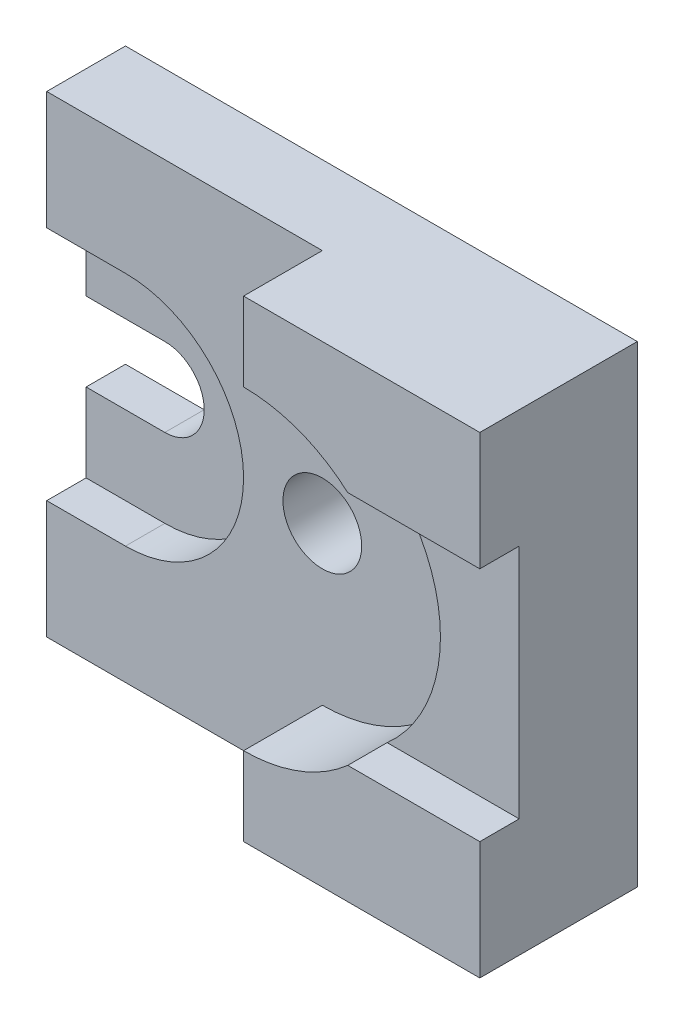
from build123d import *

# Parameters (mm, degrees)
SKETCH1_W           = 130
SKETCH1_H           = 120
BOSS_EXTRUDE1_DEPTH = 40
CUT_EXTRUDE1_DEPTH  = 40
CUT_EXTRUDE2_DEPTH  = 10
SKETCH4_R           = 10
CUT_EXTRUDE4_DEPTH  = 159
CUT_EXTRUDE5_DEPTH  = 20
SKETCH7_R           = 10
CUT_EXTRUDE6_DEPTH  = 20
CUT_EXTRUDE7_DEPTH  = 10


with BuildPart() as part:
    # Sketch1 → Boss-Extrude1 (new body)
    with BuildSketch(Plane.XY):
        with Locations((65, 60)):
            Rectangle(SKETCH1_W, SKETCH1_H)
    extrude(amount=BOSS_EXTRUDE1_DEPTH)

    # Sketch2 → Cut-Extrude1 (cut)
    with BuildSketch(Plane.XY.offset(40)):
        with BuildLine():
            Line((0, 70), (20, 70))
            ThreePointArc((20, 70), (30, 60), (20, 50))
            Line((20, 50), (0, 50))
            Line((0, 50), (0, 70))
        make_face()
    extrude(amount=-CUT_EXTRUDE1_DEPTH, mode=Mode.SUBTRACT)

    # Sketch3 → Cut-Extrude2 (cut)
    with BuildSketch(Plane.XY.offset(40)):
        with BuildLine():
            Line((20, 90), (0, 90))
            Line((0, 90), (0, 70))
            Line((0, 70), (20, 70))
            ThreePointArc((20, 70), (30, 60), (20, 50))
            Line((20, 50), (0, 50))
            Line((0, 50), (0, 30))
            Line((0, 30), (20, 30))
            ThreePointArc((20, 30), (50, 60), (20, 90))
        make_face()
    extrude(amount=-CUT_EXTRUDE2_DEPTH, mode=Mode.SUBTRACT)

    # Sketch4 → Cut-Extrude4 (cut)
    with BuildSketch(Plane.XY.offset(40)):
        with Locations((70, 60)):
            Circle(SKETCH4_R)
    extrude(amount=-CUT_EXTRUDE4_DEPTH, mode=Mode.SUBTRACT)

    # Sketch6 → Cut-Extrude5 (cut)
    with BuildSketch(Plane.XY.offset(30)):
        with BuildLine():
            Line((0, 90), (20, 90))
            ThreePointArc((20, 90), (50, 60), (20, 30))
            Line((20, 30), (0, 30))
            Line((0, 30), (0, 50))
            Line((0, 50), (20, 50))
            ThreePointArc((20, 50), (30, 60), (20, 70))
            Line((20, 70), (0, 70))
            Line((0, 70), (0, 90))
        make_face()
    extrude(amount=-CUT_EXTRUDE5_DEPTH, mode=Mode.SUBTRACT)

    # Sketch7 → Cut-Extrude6 (cut)
    with BuildSketch(Plane.XY.offset(40)):
        with BuildLine():
            Line((0, 120), (0, 90))
            Line((0, 90), (20, 90))
            ThreePointArc((20, 90), (50, 60), (20, 30))
            Line((20, 30), (0, 30))
            Line((0, 30), (0, 0))
            Line((0, 0), (70, 0))
            Line((70, 0), (70, 20))
            ThreePointArc((70, 20), (110, 60), (70, 100))
            Line((70, 100), (70, 120))
            Line((70, 120), (0, 120))
        make_face()
        with Locations((70, 60)):
            Circle(SKETCH7_R, mode=Mode.SUBTRACT)
    extrude(amount=-CUT_EXTRUDE6_DEPTH, mode=Mode.SUBTRACT)

    # Sketch8 → Cut-Extrude7 (cut)
    with BuildSketch(Plane.XY.offset(40)):
        with BuildLine():
            Line((96.457513111, 90), (130, 90))
            Line((130, 90), (130, 30))
            Line((130, 30), (96.457513111, 30))
            ThreePointArc((96.457513111, 30), (110, 60), (96.457513111, 90))
        make_face()
    extrude(amount=-CUT_EXTRUDE7_DEPTH, mode=Mode.SUBTRACT)


solid = part.part
